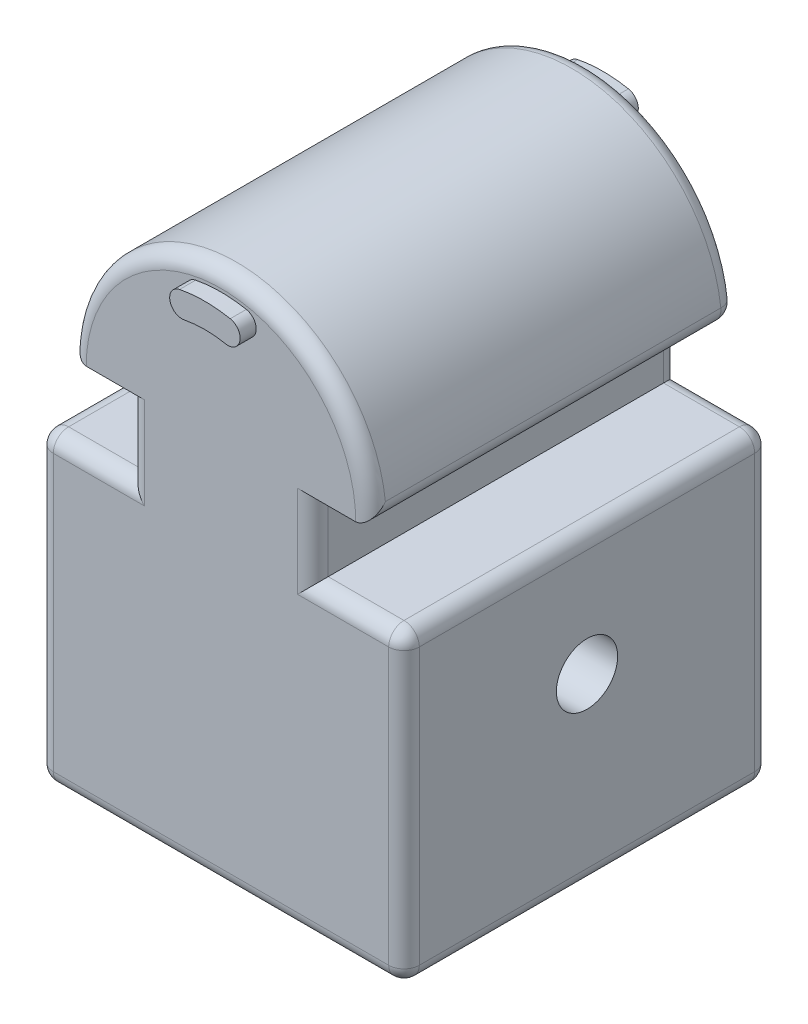
from build123d import *

# Parameters (mm, degrees)
MAIN_BODY_EXTRUDE_DEPTH   = 15.1765
SLOT_EXTRUDE_DEPTH        = 16.51
SKETCH2_W                 = 19.05
SKETCH2_H                 = 19.05
FOOT_CONNECTION_CUT_DEPTH = 22.86
PINHOLE_CUT_DEPTH         = 25.4
FILLET1_R                 = 1.27
CHAMFER2_SIZE             = 2.54
CHAMFER1_SIZE             = 2.54


with BuildPart() as part:
    # Sketch1 → Main Body Extrude (new, symmetric)
    with BuildSketch(Plane.XY):
        with BuildLine():
            ThreePointArc((12.446, 0), (0, 12.446), (-12.446, 0))
            Line((-12.446, 0), (-7.62, 0))
            Line((-7.62, 0), (-7.62, -6.35))
            Line((-7.62, -6.35), (-15.1765, -6.35))
            Line((-15.1765, -6.35), (-15.1765, -31.75))
            Line((-15.1765, -31.75), (15.1765, -31.75))
            Line((15.1765, -31.75), (15.1765, -6.35))
            Line((15.1765, -6.35), (7.62, -6.35))
            Line((7.62, -6.35), (7.62, 0))
            Line((7.62, 0), (12.446, 0))
        make_face()
        with BuildLine():
            ThreePointArc((2.100384615, 10.71813736), (2.902036033, 9.525716711), (1.709615385, 8.724065293))
            ThreePointArc((1.709615385, 8.724065293), (0, 8.89), (-1.709615385, 8.724065293))
            ThreePointArc((-1.709615385, 8.724065293), (-2.902036033, 9.525716711), (-2.100384615, 10.71813736))
            ThreePointArc((-2.100384615, 10.71813736), (0, 10.922), (2.100384615, 10.71813736))
        make_face(mode=Mode.SUBTRACT)
    extrude(amount=MAIN_BODY_EXTRUDE_DEPTH, both=True)

    # Sketch1_4 → Slot Extrude (add, symmetric)
    with BuildSketch(Plane.XY):
        with BuildLine():
            ThreePointArc((-2.100384615, 10.71813736), (-2.902036033, 9.525716711), (-1.709615385, 8.724065293))
            ThreePointArc((-1.709615385, 8.724065293), (0, 8.89), (1.709615385, 8.724065293))
            ThreePointArc((1.709615385, 8.724065293), (2.902036033, 9.525716711), (2.100384615, 10.71813736))
            ThreePointArc((2.100384615, 10.71813736), (0, 10.922), (-2.100384615, 10.71813736))
        make_face()
    extrude(amount=SLOT_EXTRUDE_DEPTH, both=True)

    # Sketch2 → Foot Connection Cut (cut)
    with BuildSketch(Plane.XZ.offset(31.75)):
        Rectangle(SKETCH2_W, SKETCH2_H)
    extrude(amount=-FOOT_CONNECTION_CUT_DEPTH, mode=Mode.SUBTRACT)

    # Sketch4 → Pinhole Cut (cut, symmetric)
    with BuildSketch(Plane(origin=(-9.525, 0, 0), x_dir=(0, 0, -1), z_dir=(1, 0, 0))):
        with BuildLine():
            ThreePointArc((2.54, -16.51), (1.796051224, -14.713948776), (0, -13.97))
            ThreePointArc((0, -13.97), (-1.796051224, -18.306051224), (2.54, -16.51))
        make_face()
    extrude(amount=PINHOLE_CUT_DEPTH, both=True, mode=Mode.SUBTRACT)

    # Fillet1
    fillet1_edges = [part.edges().sort_by_distance(p)[0] for p in [
        (11.39825, -6.35, 15.1765),
        (12.446, 0, 0),
        (15.1765, -6.35, 0),
        (7.62, -3.175, 15.1765),
        (-11.39825, -6.35, 15.1765),
        (-15.1765, -6.35, 0),
        (-7.62, -3.175, 15.1765),
        (-12.446, 0, 0),
        (0, 12.446, 15.1765),
        (11.39825, -6.35, -15.1765),
        (7.62, -3.175, -15.1765),
        (10.033, 0, -15.1765),
        (-10.033, 0, -15.1765),
        (-7.62, -3.175, -15.1765),
        (-11.39825, -6.35, -15.1765),
        (0, 12.446, -15.1765),
        (15.1765, -31.75, 0),
        (-15.1765, -31.75, 0),
        (0, -31.75, 15.1765),
        (0, -31.75, -15.1765),
        (-15.1765, -19.05, -15.1765),
        (-15.1765, -19.05, 15.1765),
        (15.1765, -19.05, 15.1765),
        (15.1765, -19.05, -15.1765),
    ]]
    fillet(fillet1_edges, radius=FILLET1_R)

    # Chamfer2
    chamfer2_edges = [part.edges().sort_by_distance(p)[0] for p in [
        (-9.525, -20.32, -9.525),
        (-9.525, -20.32, 9.525),
        (9.525, -20.32, -9.525),
        (9.525, -20.32, 9.525),
    ]]
    chamfer(chamfer2_edges, length=CHAMFER2_SIZE)

    # Chamfer1
    chamfer1_edges = [part.edges().sort_by_distance(p)[0] for p in [
        (9.525, -31.75, 0),
        (0, -31.75, -9.525),
        (0, -31.75, 9.525),
        (-9.525, -31.75, 0),
        (-8.255, -31.75, 8.255),
        (8.255, -31.75, 8.255),
        (8.255, -31.75, -8.255),
        (-8.255, -31.75, -8.255),
    ]]
    chamfer(chamfer1_edges, length=CHAMFER1_SIZE)


solid = part.part
